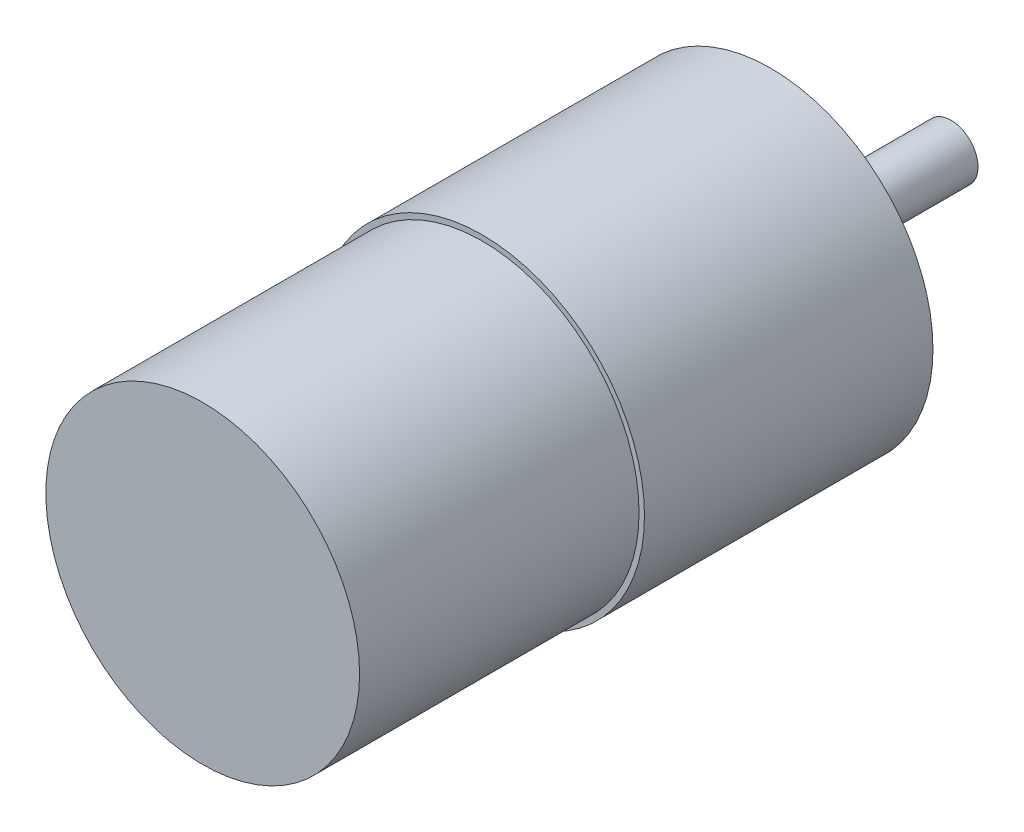
from build123d import *

# Parameters (mm, degrees)
SKETCH_1_R          = 18
EXTRUDE_1_DEPTH     = 32
SKETCH_2_R          = 17.4
EXTRUDE_2_DEPTH     = 31
SKETCH_3_R          = 11
EXTRUDE_3_DEPTH     = 2
SKETCH_4_R          = 4
EXTRUDE_4_DEPTH     = 3
SKETCH_5_R          = 3
EXTRUDE_5_DEPTH     = 15
SKETCH_6_R          = 1.5
CUT_EXTRUDE_2_DEPTH = 5


with BuildPart() as part:
    # 草图1 → 凸台-拉伸1 (new body)
    with BuildSketch(Plane.XY):
        Circle(SKETCH_1_R)
    extrude(amount=EXTRUDE_1_DEPTH)

    # 草图2 → 凸台-拉伸2 (add)
    with BuildSketch(Plane.XY.offset(32)):
        Circle(SKETCH_2_R)
    extrude(amount=EXTRUDE_2_DEPTH)

    # 草图3 → 凸台-拉伸3 (add)
    with BuildSketch(Plane(origin=(0, 0, 0), x_dir=(-1, 0, 0), z_dir=(0, 0, -1))):
        Circle(SKETCH_3_R)
    extrude(amount=EXTRUDE_3_DEPTH)

    # 草图4 → 凸台-拉伸4 (add)
    with BuildSketch(Plane(origin=(0, 0, -2), x_dir=(-1, 0, 0), z_dir=(0, 0, -1))):
        Circle(SKETCH_4_R)
    extrude(amount=EXTRUDE_4_DEPTH)

    # 草图5 → 凸台-拉伸5 (add)
    with BuildSketch(Plane(origin=(0, 0, -5), x_dir=(-1, 0, 0), z_dir=(0, 0, -1))):
        Circle(SKETCH_5_R)
    extrude(amount=EXTRUDE_5_DEPTH)

    # 草图6 → 切除-拉伸2 (cut)
    with BuildSketch(Plane(origin=(0, 0, 0), x_dir=(-1, 0, 0), z_dir=(0, 0, -1))):
        with Locations((0, 14)):
            Circle(SKETCH_6_R)
        with Locations((0, -14)):
            Circle(SKETCH_6_R)
        with Locations((14, 0)):
            Circle(SKETCH_6_R)
        with Locations((-14, 0)):
            Circle(SKETCH_6_R)
    extrude(amount=-CUT_EXTRUDE_2_DEPTH, mode=Mode.SUBTRACT)


solid = part.part
